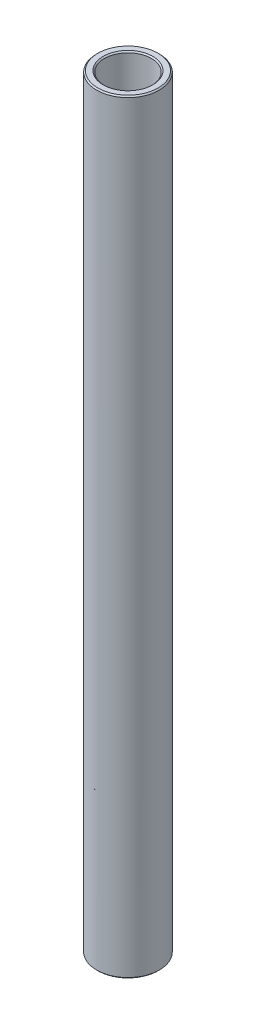
from build123d import *

# Parameters (mm, degrees)
SKETCH1_W     = 1.5875
SKETCH1_H     = 154.78125
CHAMFER1_SIZE = 0.254


with BuildPart() as part:
    # Sketch1 → Revolve1 (revolve)
    with BuildSketch(Plane.XY):
        with Locations((5.55625, 0)):
            Rectangle(SKETCH1_W, SKETCH1_H)
    revolve(axis=Axis((0, 11.60859375, 0), (0, -1, 0)))

    # Chamfer1
    chamfer1_edges = [part.edges().sort_by_distance(p)[0] for p in [
        (-4.7625, -77.390625, 0),
        (-6.35, -77.390625, 0),
        (-6.35, 77.390625, 0),
        (-4.7625, 77.390625, 0),
    ]]
    chamfer(chamfer1_edges, length=CHAMFER1_SIZE)


solid = part.part
